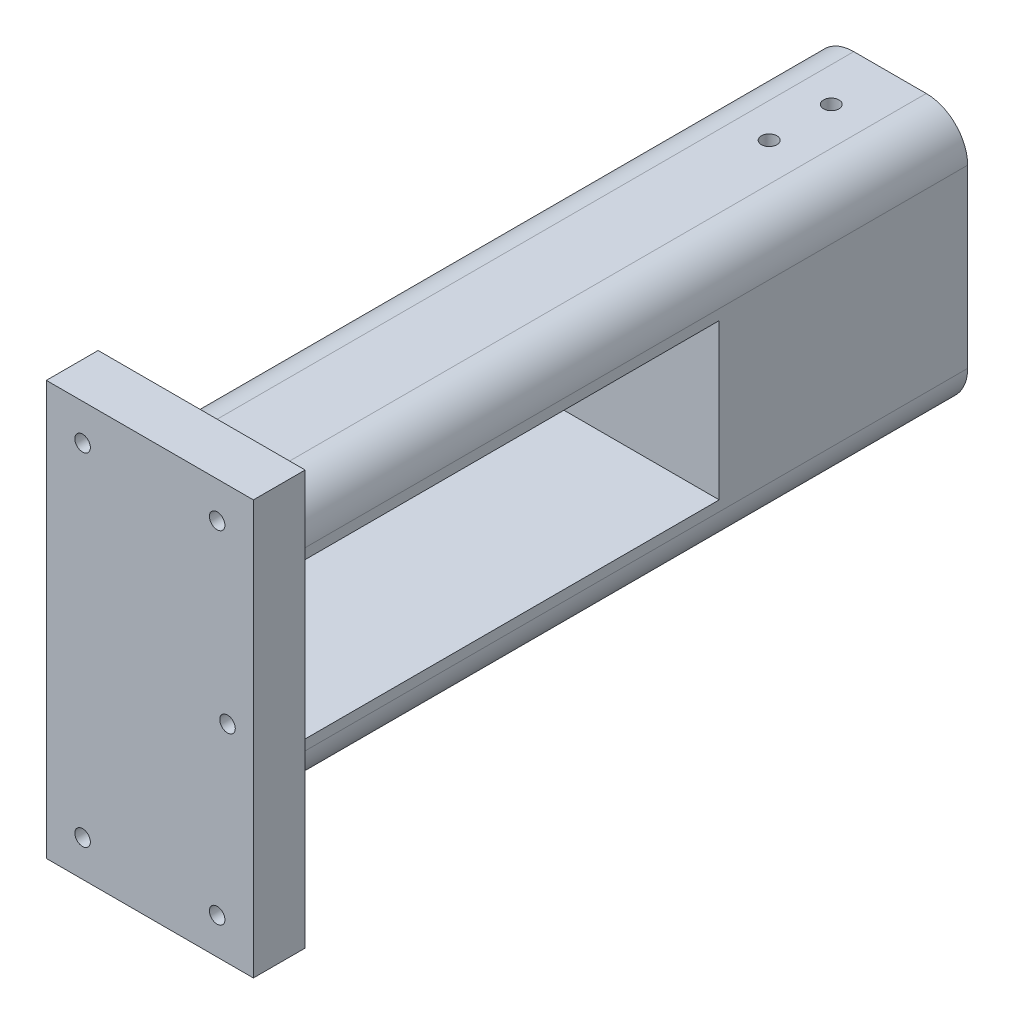
from build123d import *

# Parameters (mm, degrees)
SKETCH1_W               = 40
SKETCH1_H               = 80
BOSS_EXTRUDE1_DEPTH     = 10
SKETCH2_W               = 30
SKETCH2_H               = 50
BOSS_EXTRUDE2_DEPTH     = 100
SKETCH4_W               = 80
SKETCH4_H               = 30
CUT_EXTRUDE1_DEPTH      = 150
SKETCH3_W               = 30
SKETCH3_H               = 50
SKETCH3_W_2             = 15.3
SKETCH3_H_2             = 30.5
BOSS_EXTRUDE3_DEPTH     = 38
FILLET1_R               = 8
FILLET2_R               = 8
FILLET3_R               = 8
FILLET4_R               = 8
SKETCH5_R               = 1.5
CUT_EXTRUDE2_DEPTH      = 56
CUT_EXTRUDE2_DEPTH_BACK = 26
SKETCH6_R               = 1.5
CUT_EXTRUDE3_DEPTH      = 40


with BuildPart() as part:
    # Sketch1 → Boss-Extrude1 (new body)
    with BuildSketch(Plane.XY):
        with Locations((-7.998819607, 5.424203747)):
            Rectangle(SKETCH1_W, SKETCH1_H)
    extrude(amount=BOSS_EXTRUDE1_DEPTH)

    # Sketch2 → Boss-Extrude2 (add)
    with BuildSketch(Plane(origin=(0, 0, 0), x_dir=(-1, 0, 0), z_dir=(0, 0, -1))):
        with Locations((12.998819607, 5.424203747)):
            Rectangle(SKETCH2_W, SKETCH2_H)
    extrude(amount=BOSS_EXTRUDE2_DEPTH)

    # Sketch4 → Cut-Extrude1 (cut)
    with BuildSketch(Plane.ZY.offset(27.998819607)):
        with Locations((-50, 5.424203747)):
            Rectangle(SKETCH4_W, SKETCH4_H)
    extrude(amount=-CUT_EXTRUDE1_DEPTH, mode=Mode.SUBTRACT)

    # Sketch3 → Boss-Extrude3 (add)
    with BuildSketch(Plane(origin=(0, 0, -100), x_dir=(-1, 0, 0), z_dir=(0, 0, -1))):
        with Locations((12.998819607, 5.424203747)):
            Rectangle(SKETCH3_W, SKETCH3_H)
        with Locations((13.348819607, 5.174203747)):
            Rectangle(SKETCH3_W_2, SKETCH3_H_2, mode=Mode.SUBTRACT)
    extrude(amount=BOSS_EXTRUDE3_DEPTH)

    # Fillet1
    fillet1_edges = [part.edges().sort_by_distance(p)[0] for p in [
        (2.001180393, -19.575796253, -69),
    ]]
    fillet(fillet1_edges, radius=FILLET1_R)

    # Fillet2
    fillet2_edges = [part.edges().sort_by_distance(p)[0] for p in [
        (2.001180393, 30.424203747, -69),
    ]]
    fillet(fillet2_edges, radius=FILLET2_R)

    # Fillet3
    fillet3_edges = [part.edges().sort_by_distance(p)[0] for p in [
        (-27.998819607, -19.575796253, -69),
    ]]
    fillet(fillet3_edges, radius=FILLET3_R)

    # Fillet4
    fillet4_edges = [part.edges().sort_by_distance(p)[0] for p in [
        (-27.998819607, 30.424203747, -69),
    ]]
    fillet(fillet4_edges, radius=FILLET4_R)

    # Sketch5 → Cut-Extrude2 (cut, two sides)
    with BuildSketch(Plane.XZ.offset(-20.424203747)) as cut_extrude2_sk:
        with Locations((-13.348819607, -115)):
            Circle(SKETCH5_R)
        with Locations((-13.348819607, -127)):
            Circle(SKETCH5_R)
    extrude(amount=CUT_EXTRUDE2_DEPTH, mode=Mode.SUBTRACT)
    extrude(cut_extrude2_sk.sketch, amount=-CUT_EXTRUDE2_DEPTH_BACK, mode=Mode.SUBTRACT)

    # Sketch6 → Cut-Extrude3 (cut)
    with BuildSketch(Plane(origin=(0, 0, 0), x_dir=(-1, 0, 0), z_dir=(0, 0, -1))):
        with Locations((20.998819607, 38.424203747)):
            Circle(SKETCH6_R)
        with Locations((-5.001180393, 38.424203747)):
            Circle(SKETCH6_R)
        with Locations((20.998819607, -27.575796253)):
            Circle(SKETCH6_R)
        with Locations((-5.001180393, -27.575796253)):
            Circle(SKETCH6_R)
        with Locations((-7.001180393, 5.424203747)):
            Circle(SKETCH6_R)
    extrude(amount=-CUT_EXTRUDE3_DEPTH, mode=Mode.SUBTRACT)


solid = part.part
